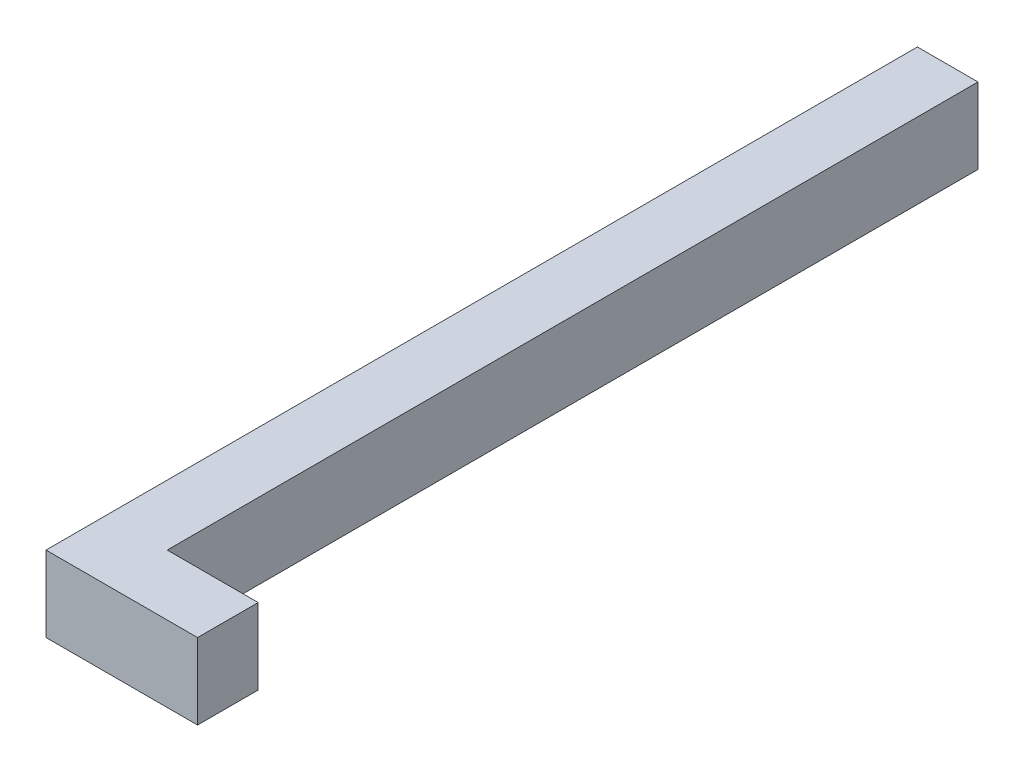
from build123d import *

# Parameters (mm, degrees)
SKETCH1_W           = 8
SKETCH1_H           = 10
BOSS_EXTRUDE1_DEPTH = 115
SKETCH2_W           = 3.8
SKETCH2_H           = 3.8
BOSS_EXTRUDE2_DEPTH = 1.8
SKETCH4_W           = 8
SKETCH4_H           = 10
BOSS_EXTRUDE4_DEPTH = 12
SKETCH5_R           = 2.6
CUT_EXTRUDE1_DEPTH  = 3


with BuildPart() as part:
    # Sketch1 → Boss-Extrude1 (new body)
    with BuildSketch(Plane.XY):
        with Locations((4, 5)):
            Rectangle(SKETCH1_W, SKETCH1_H)
    extrude(amount=BOSS_EXTRUDE1_DEPTH)

    # Sketch2 → Boss-Extrude2 (add)
    with BuildSketch(Plane(origin=(0, 0, 0), x_dir=(-1, 0, 0), z_dir=(0, 0, -1))):
        with Locations((-4, 5)):
            Rectangle(SKETCH2_W, SKETCH2_H)
    extrude(amount=BOSS_EXTRUDE2_DEPTH)

    # Sketch4 → Boss-Extrude4 (add)
    with BuildSketch(Plane(origin=(8, 0, 0), x_dir=(0, 0, -1), z_dir=(1, 0, 0))):
        with Locations((-111, 5)):
            Rectangle(SKETCH4_W, SKETCH4_H)
    extrude(amount=BOSS_EXTRUDE4_DEPTH)

    # Sketch5 → Cut-Extrude1 (cut)
    with BuildSketch(Plane.ZY):
        with Locations((30, 5)):
            Circle(SKETCH5_R)
    extrude(amount=-CUT_EXTRUDE1_DEPTH, mode=Mode.SUBTRACT)


solid = part.part
